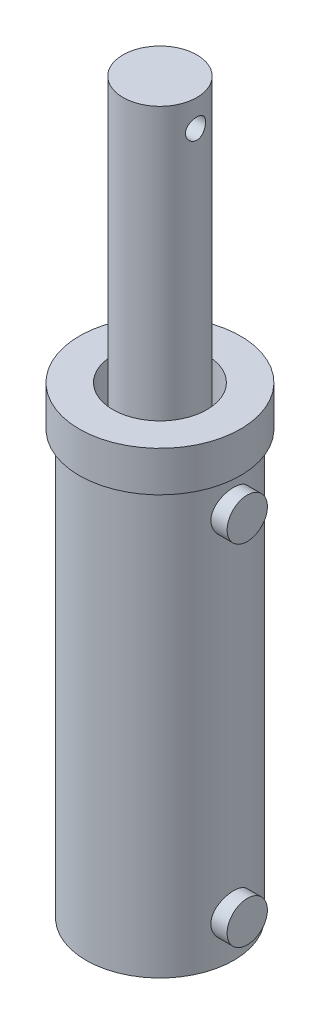
from build123d import *

# Parameters (mm, degrees)
SKETCH1_R               = 69.85
BOSS_EXTRUDE1_DEPTH     = 438.15
SKETCH5_R               = 76.2
BOSS_EXTRUDE5_DEPTH     = 38.1
SKETCH6_R               = 44.45
CUT_EXTRUDE1_DEPTH      = 38.1
BOSS_EXTRUDE7_START     = -12.7
SKETCH8_R               = 19.05
BOSS_EXTRUDE7_DEPTH     = 15.347917
SKETCH9_R               = 34.925
BOSS_EXTRUDE8_DEPTH     = 288.925
SKETCH10_R              = 9.525
CUT_EXTRUDE2_DEPTH      = 83.5500001
CUT_EXTRUDE2_DEPTH_BACK = 77.2


with BuildPart() as part:
    # Sketch1 → Boss-Extrude1 (new body)
    with BuildSketch(Plane(origin=(0, 0, 0), x_dir=(1, 0, 0), z_dir=(0, 1, 0))):
        Circle(SKETCH1_R)
    extrude(amount=BOSS_EXTRUDE1_DEPTH)

    # Sketch5 → Boss-Extrude5 (add)
    with BuildSketch(Plane(origin=(0, 438.15, 0), x_dir=(-1, 0, 0), z_dir=(0, 1, 0))):
        Circle(SKETCH5_R)
    extrude(amount=-BOSS_EXTRUDE5_DEPTH)

    # Sketch6 → Cut-Extrude1 (cut)
    with BuildSketch(Plane(origin=(0, 438.15, 0), x_dir=(1, 0, 0), z_dir=(0, 1, 0))):
        Circle(SKETCH6_R)
    extrude(amount=-CUT_EXTRUDE1_DEPTH, mode=Mode.SUBTRACT)

    # Sketch8 → Boss-Extrude7 (add)
    with BuildSketch(Plane.ZY.offset(-69.85).offset(BOSS_EXTRUDE7_START)):
        with Locations((0, 368.3)):
            Circle(SKETCH8_R)
        with Locations((0, 38.1)):
            Circle(SKETCH8_R)
    extrude(amount=BOSS_EXTRUDE7_DEPTH)

    # Sketch9 → Boss-Extrude8 (add)
    with BuildSketch(Plane(origin=(0, 400.05, 0), x_dir=(1, 0, 0), z_dir=(0, 1, 0))):
        Circle(SKETCH9_R)
    extrude(amount=BOSS_EXTRUDE8_DEPTH)

    # Sketch10 → Cut-Extrude2 (cut, two sides)
    with BuildSketch(Plane(origin=(0, 0, 0), x_dir=(0, 0, -1), z_dir=(1, 0, 0))) as cut_extrude2_sk:
        with Locations((0, 663.575)):
            Circle(SKETCH10_R)
    extrude(amount=CUT_EXTRUDE2_DEPTH, mode=Mode.SUBTRACT)
    extrude(cut_extrude2_sk.sketch, amount=-CUT_EXTRUDE2_DEPTH_BACK, mode=Mode.SUBTRACT)


solid = part.part
